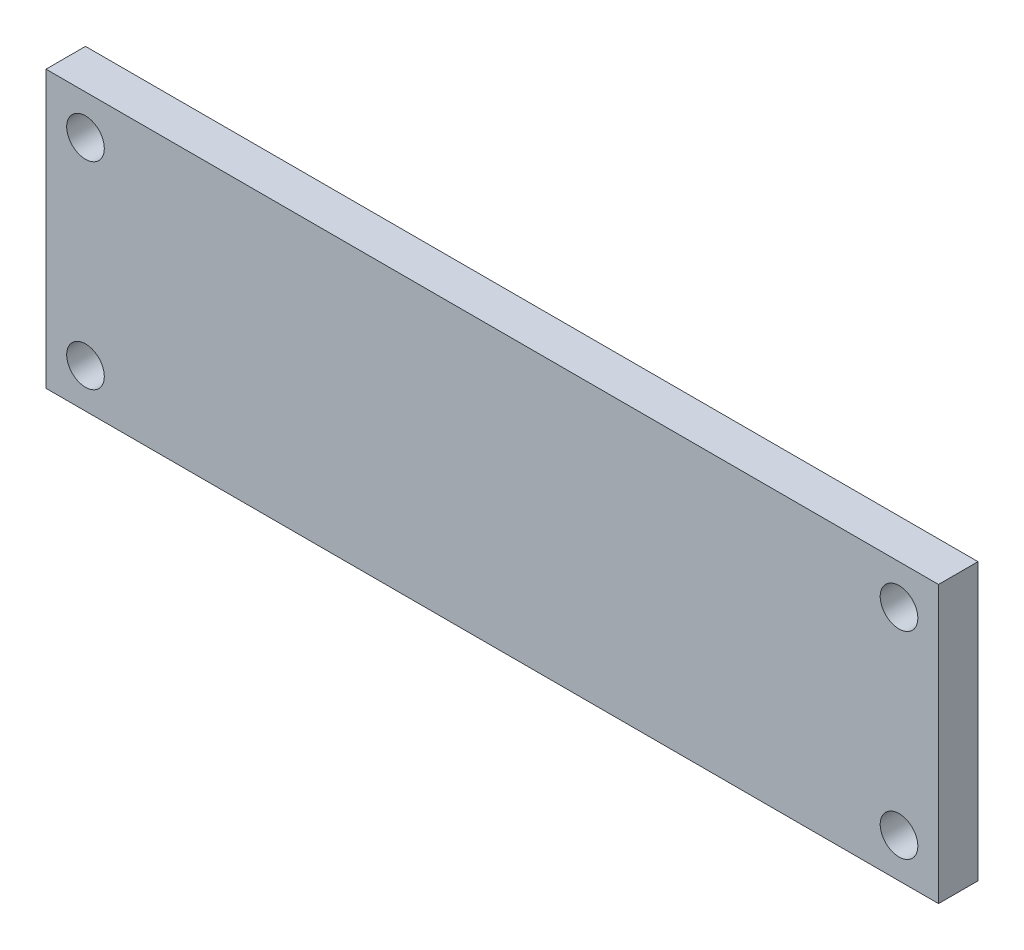
from build123d import *

# Parameters (mm, degrees)
SKETCH1_W           = 113
SKETCH1_H           = 35
SKETCH1_R           = 2.38125
BOSS_EXTRUDE1_DEPTH = 5


with BuildPart() as part:
    # Sketch1 → Boss-Extrude1 (new body)
    with BuildSketch(Plane.XY):
        with Locations((56.5, 17.5)):
            Rectangle(SKETCH1_W, SKETCH1_H)
        with Locations((5, 5)):
            Circle(SKETCH1_R, mode=Mode.SUBTRACT)
        with Locations((5, 30)):
            Circle(SKETCH1_R, mode=Mode.SUBTRACT)
        with Locations((108, 30)):
            Circle(SKETCH1_R, mode=Mode.SUBTRACT)
        with Locations((108, 5)):
            Circle(SKETCH1_R, mode=Mode.SUBTRACT)
    extrude(amount=BOSS_EXTRUDE1_DEPTH)


solid = part.part
